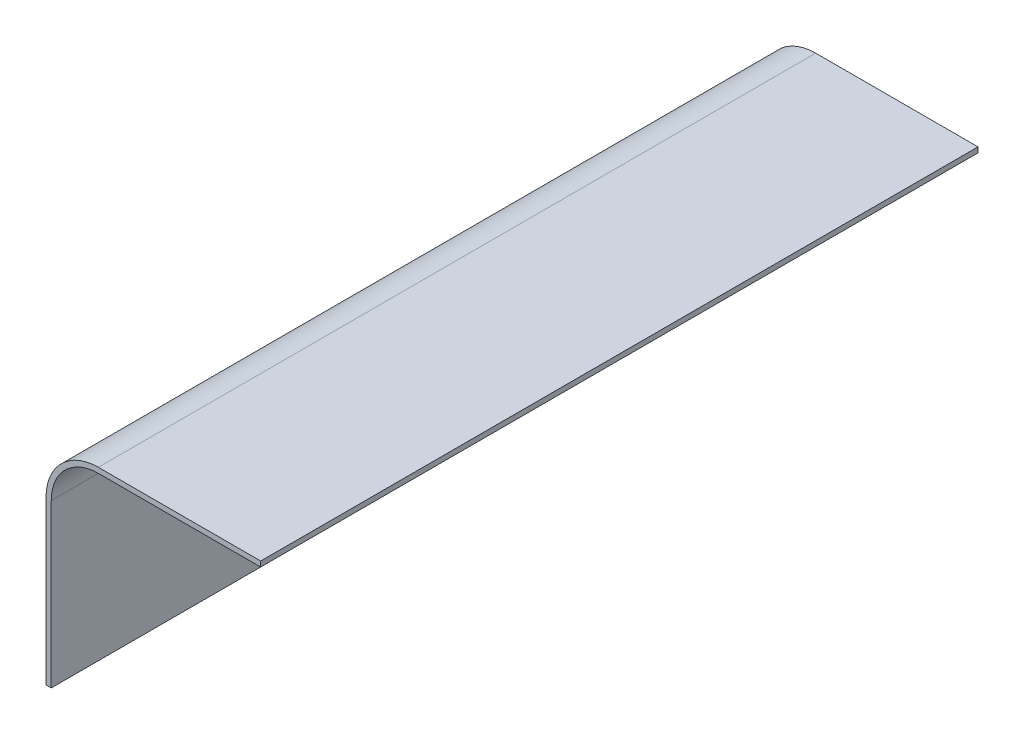
from build123d import *

# Parameters (mm, degrees)
BOSS_EXTRUDE1_DEPTH = 274


with BuildPart() as part:
    # Sketch1 → Boss-Extrude1 (new body)
    with BuildSketch(Plane.XY):
        with BuildLine():
            Line((0, 0), (0, 62))
            ThreePointArc((0, 62), (5.272077939, 74.727922061), (18, 80))
            Line((18, 80), (80, 80))
            Line((80, 80), (80, 82))
            Line((80, 82), (18, 82))
            ThreePointArc((18, 82), (3.857864376, 76.142135624), (-2, 62))
            Line((-2, 62), (-2, 0))
            Line((-2, 0), (0, 0))
        make_face()
    extrude(amount=-BOSS_EXTRUDE1_DEPTH)


solid = part.part
